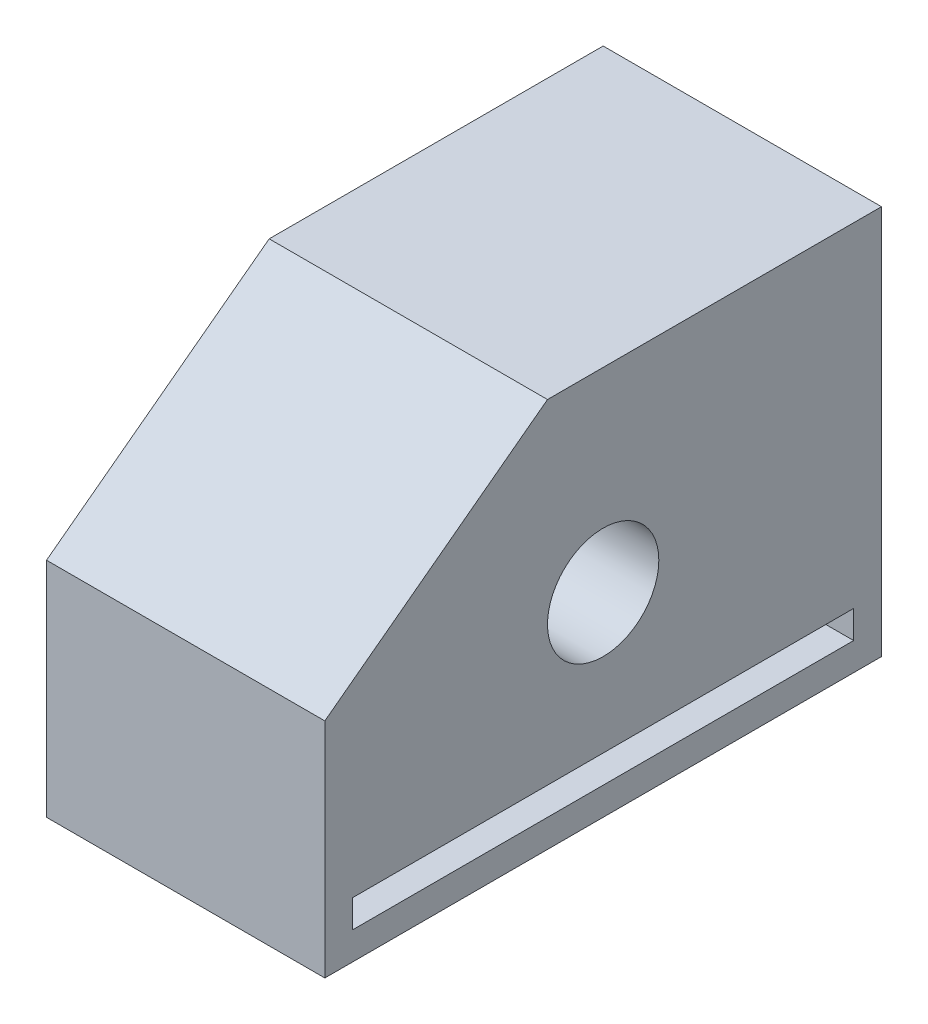
from build123d import *

# Parameters (mm, degrees)
BOSS_EXTRUDE1_DEPTH = 50
SKETCH2_R           = 10
CUT_EXTRUDE1_DEPTH  = 51
SKETCH3_W           = 90
SKETCH3_H           = 5
CUT_EXTRUDE2_DEPTH  = 51


with BuildPart() as part:
    # Sketch1 → Boss-Extrude1 (new body)
    with BuildSketch(Plane(origin=(0, 0, 0), x_dir=(0, 0, -1), z_dir=(1, 0, 0))):
        Polygon((40, 70), (0, 40), (0, 0), (100, 0), (100, 70), align=None)
    extrude(amount=BOSS_EXTRUDE1_DEPTH)

    # Sketch2 → Cut-Extrude1 (cut, through all)
    with BuildSketch(Plane(origin=(50, 0, 0), x_dir=(0, 0, -1), z_dir=(1, 0, 0))):
        with Locations((50, 35)):
            Circle(SKETCH2_R)
    extrude(amount=-CUT_EXTRUDE1_DEPTH, mode=Mode.SUBTRACT)

    # Sketch3 → Cut-Extrude2 (cut, through all)
    with BuildSketch(Plane(origin=(50, 0, 0), x_dir=(0, 0, -1), z_dir=(1, 0, 0))):
        with Locations((50, 7.5)):
            Rectangle(SKETCH3_W, SKETCH3_H)
    extrude(amount=-CUT_EXTRUDE2_DEPTH, mode=Mode.SUBTRACT)


solid = part.part
